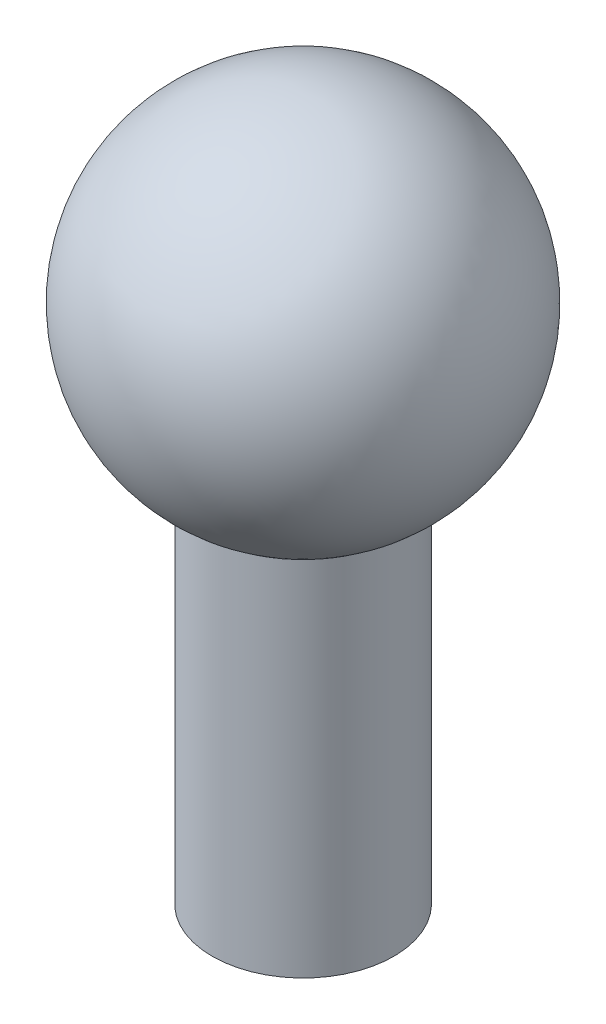
from build123d import *

# Parameters (mm, degrees)
ESQUISSE2_R             = 10
BOSS_EXTRU_2_DEPTH      = 40
ESQUISSE3_R             = 7.25
ENL_V_MAT_EXTRU_1_DEPTH = 30
CONG_2_R                = 2


with BuildPart() as part:
    # Esquisse2 → Boss.-Extru.2 (new body)
    with BuildSketch(Plane(origin=(0, 0, 0), x_dir=(1, 0, 0), z_dir=(0, 1, 0))):
        Circle(ESQUISSE2_R)
    extrude(amount=BOSS_EXTRU_2_DEPTH)

    # Esquisse3 → Enlèv. mat.-Extru.1 (cut)
    with BuildSketch(Plane.XZ):
        Circle(ESQUISSE3_R)
    extrude(amount=-ENL_V_MAT_EXTRU_1_DEPTH, mode=Mode.SUBTRACT)

    # Congé2
    cong_2_edges = [part.edges().sort_by_distance(p)[0] for p in [
        (-7.25, 30, 0),
    ]]
    fillet(cong_2_edges, radius=CONG_2_R)

    # Esquisse9 → Révolution7 (revolve)
    with BuildSketch(Plane(origin=(0, 0, 0), x_dir=(0, 0, -1), z_dir=(1, 0, 0))):
        with BuildLine():
            Line((20, 57.326780647), (-20, 57.326780647))
            ThreePointArc((-20, 57.326780647), (0, 37.326780647), (20, 57.326780647))
        make_face()
    revolve(axis=Axis((0, 57.326780647, -20), (0, 0, 1)))


solid = part.part
